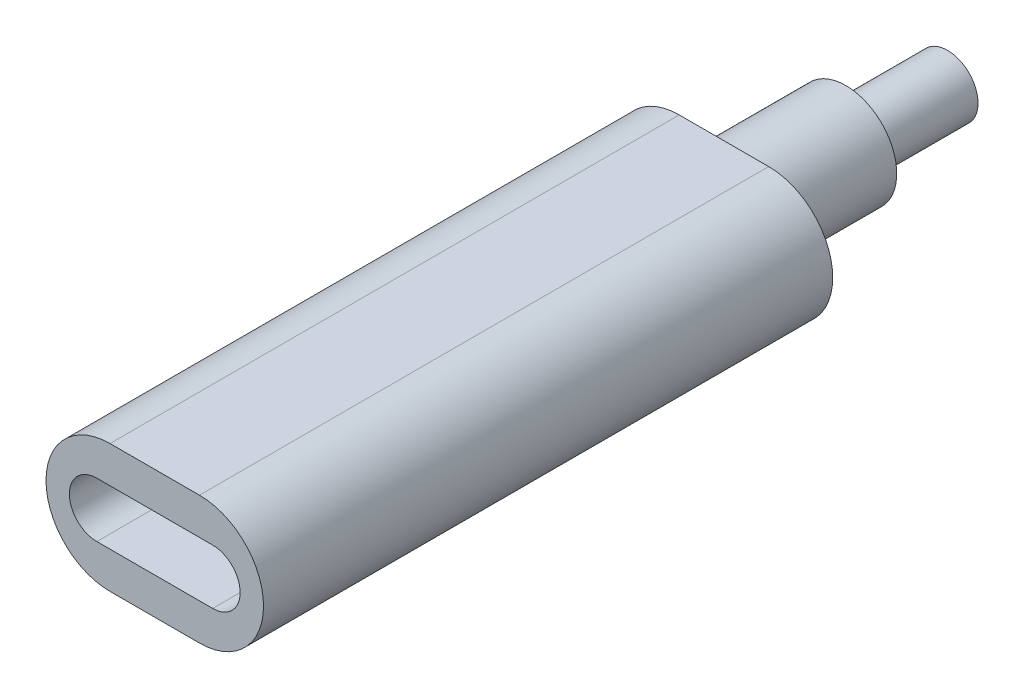
from build123d import *

# Parameters (mm, degrees)
BOSS_EXTRUDE1_DEPTH = 28
CUT_EXTRUDE1_DEPTH  = 5
SKETCH3_R           = 2.5
BOSS_EXTRUDE2_DEPTH = 6
SKETCH4_R           = 1.5
BOSS_EXTRUDE3_DEPTH = 5


with BuildPart() as part:
    # Sketch1 → Boss-Extrude1 (new body)
    with BuildSketch(Plane.XY):
        with BuildLine():
            Line((2.2, -3.15), (-2.2, -3.15))
            ThreePointArc((-2.2, -3.15), (-5.35, 0), (-2.2, 3.15))
            Line((-2.2, 3.15), (2.2, 3.15))
            ThreePointArc((2.2, 3.15), (5.35, 0), (2.2, -3.15))
        make_face()
    extrude(amount=-BOSS_EXTRUDE1_DEPTH)

    # Sketch1_3 → Cut-Extrude1 (cut)
    with BuildSketch(Plane.XY):
        with BuildLine():
            Line((2.85, -1.35), (-2.85, -1.35))
            ThreePointArc((-2.85, -1.35), (-4.2, 0), (-2.85, 1.35))
            Line((-2.85, 1.35), (2.85, 1.35))
            ThreePointArc((2.85, 1.35), (4.2, 0), (2.85, -1.35))
        make_face()
    extrude(amount=-CUT_EXTRUDE1_DEPTH, mode=Mode.SUBTRACT)

    # Sketch3 → Boss-Extrude2 (add)
    with BuildSketch(Plane(origin=(0, 0, -28), x_dir=(-1, 0, 0), z_dir=(0, 0, -1))):
        Circle(SKETCH3_R)
    extrude(amount=BOSS_EXTRUDE2_DEPTH)

    # Sketch4 → Boss-Extrude3 (add)
    with BuildSketch(Plane(origin=(0, 0, -34), x_dir=(-1, 0, 0), z_dir=(0, 0, -1))):
        Circle(SKETCH4_R)
    extrude(amount=BOSS_EXTRUDE3_DEPTH)


solid = part.part
